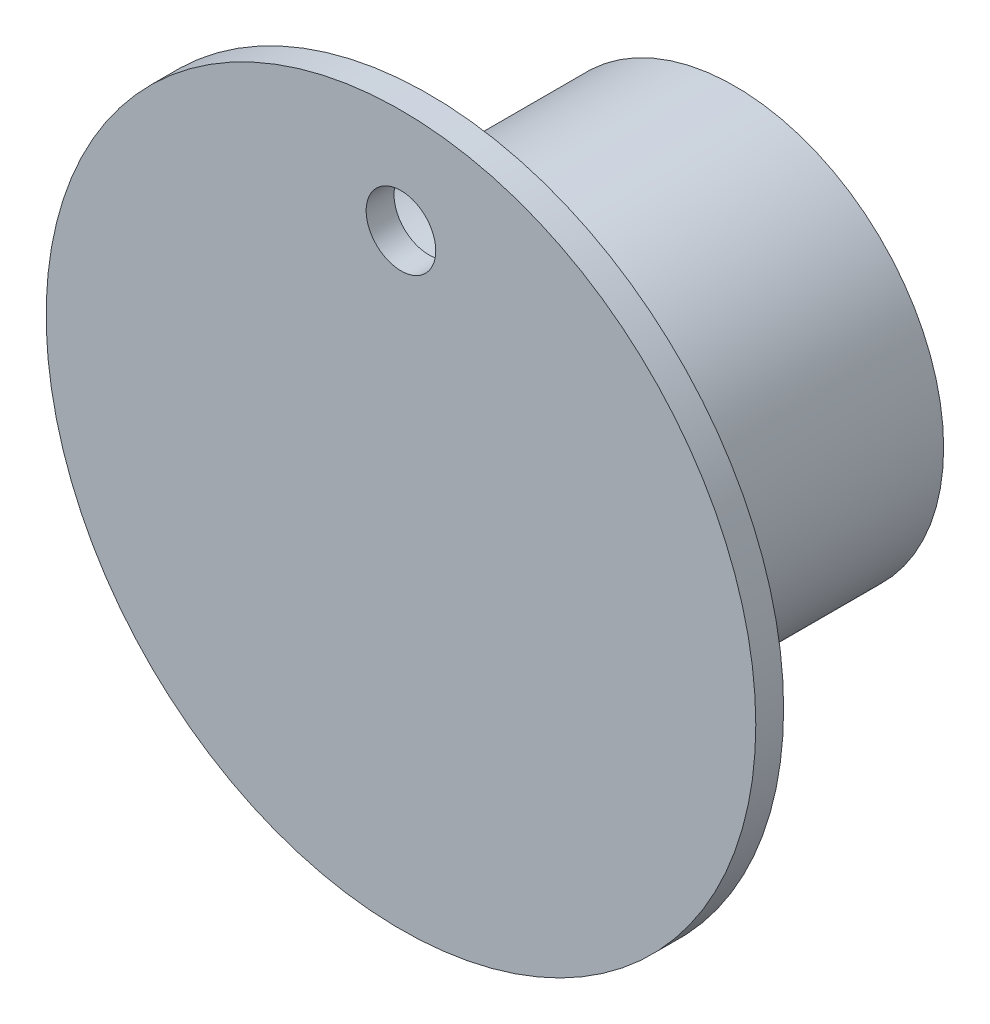
from build123d import *

# Parameters (mm, degrees)
ESQUISSE1_R             = 25.5
BOSS_EXTRU_1_DEPTH      = 2
ESQUISSE2_R             = 15
ESQUISSE2_R_2           = 10
BOSS_EXTRU_2_DEPTH      = 22
ESQUISSE3_R             = 2.5
ENL_V_MAT_EXTRU_1_DEPTH = 2


with BuildPart() as part:
    # Esquisse1 → Boss.-Extru.1 (new body)
    with BuildSketch(Plane.XY):
        Circle(ESQUISSE1_R)
    extrude(amount=BOSS_EXTRU_1_DEPTH)

    # Esquisse2 → Boss.-Extru.2 (add)
    with BuildSketch(Plane(origin=(0, 0, 0), x_dir=(-1, 0, 0), z_dir=(0, 0, -1))):
        Circle(ESQUISSE2_R)
        Circle(ESQUISSE2_R_2, mode=Mode.SUBTRACT)
    extrude(amount=BOSS_EXTRU_2_DEPTH)

    # Esquisse3 → Enlèv. mat.-Extru.1 (cut)
    with BuildSketch(Plane.XY.offset(2)):
        with Locations((0, 18)):
            Circle(ESQUISSE3_R)
    extrude(amount=-ENL_V_MAT_EXTRU_1_DEPTH, mode=Mode.SUBTRACT)


solid = part.part
